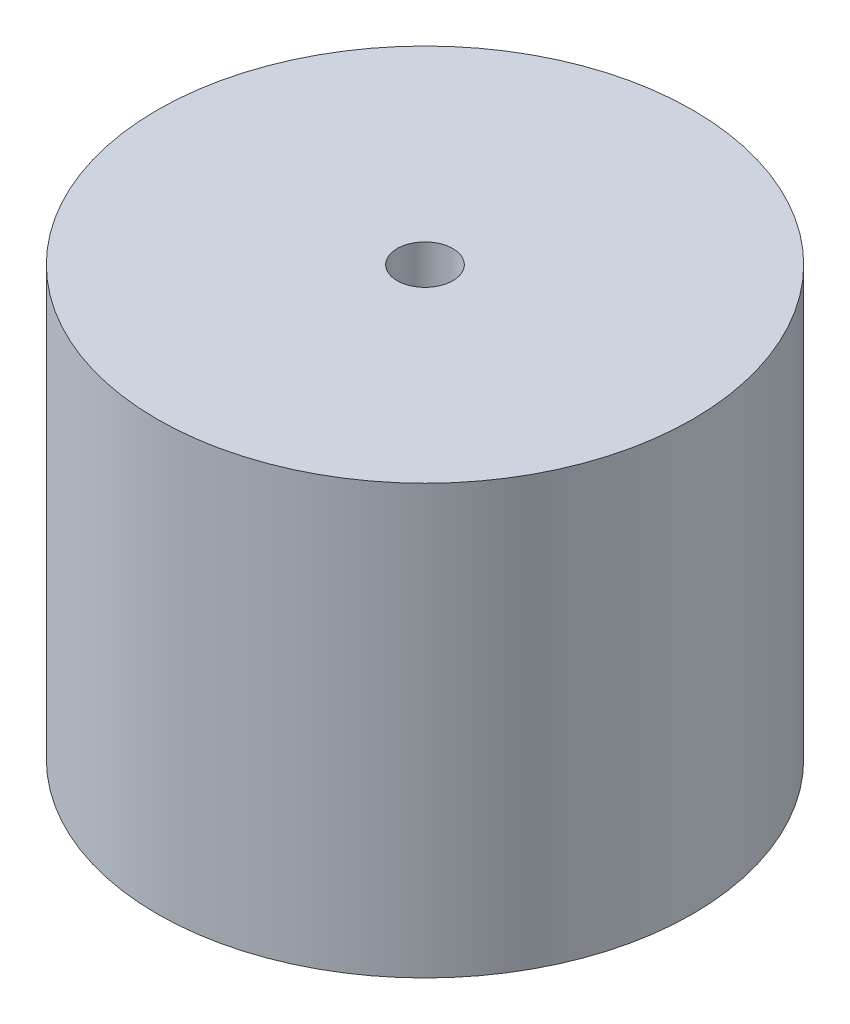
from build123d import *

# Parameters (mm, degrees)
SKETCH1_R           = 3.175
SKETCH1_R_2         = 0.3302
BOSS_EXTRUDE2_DEPTH = 2.54
SKETCH3_R           = 3.175
BOSS_EXTRUDE3_DEPTH = 2.54


with BuildPart() as part:
    # Sketch1 → Boss-Extrude2 (new body)
    with BuildSketch(Plane(origin=(0, 0, 0), x_dir=(1, 0, 0), z_dir=(0, 1, 0))):
        with Locations((-32.44000105, -6.278709881)):
            Circle(SKETCH1_R)
        with Locations((-32.44000105, -6.278709881)):
            Circle(SKETCH1_R_2, mode=Mode.SUBTRACT)
    extrude(amount=BOSS_EXTRUDE2_DEPTH)

    # Sketch3 → Boss-Extrude3 (add)
    with BuildSketch(Plane.XZ):
        with Locations((-32.44000105, 6.278709881)):
            Circle(SKETCH3_R)
    extrude(amount=BOSS_EXTRUDE3_DEPTH)


solid = part.part
